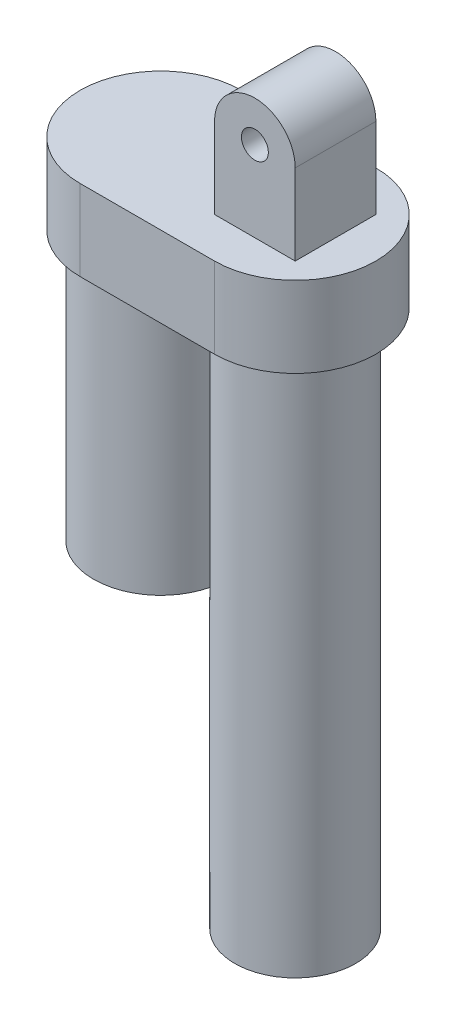
from build123d import *

# Parameters (mm, degrees)
ESBO_O1_W                = 13.5
ESBO_O1_H                = 200
RESSALTO_EXTRUS_O1_DEPTH = 30
ESBO_O3_W                = 25
ESBO_O3_H                = 100
ESBO_O4_R                = 5
RESSALTO_EXTRUS_O2_DEPTH = 15


with BuildPart() as part:
    # Esboço1 → Revolução1 (revolve)
    with BuildSketch(Plane.XY):
        with Locations((15.75, 100)):
            Rectangle(ESBO_O1_W, ESBO_O1_H)
    revolve(axis=Axis((0, 0, 0), (0, 1, 0)))

    # Esboço2 → Ressalto-extrusão1 (add)
    with BuildSketch(Plane(origin=(0, 200, 0), x_dir=(1, 0, 0), z_dir=(0, 1, 0))):
        with BuildLine():
            Line((0, -30), (-50, -30))
            ThreePointArc((-50, -30), (-80, 0), (-50, 30))
            Line((-50, 30), (0, 30))
            ThreePointArc((0, 30), (30, 0), (0, -30))
        make_face()
    extrude(amount=RESSALTO_EXTRUS_O1_DEPTH)

    # Esboço3 → Revolução2 (revolve)
    with BuildSketch(Plane.XY):
        with Locations((-37.5, 150)):
            Rectangle(ESBO_O3_W, ESBO_O3_H)
    revolve(axis=Axis((-50, 200, 0), (0, -1, 0)))

    # Esboço4 → Ressalto-extrusão2 (add, symmetric)
    with BuildSketch(Plane.XY):
        with BuildLine():
            Line((15, 230), (15, 260))
            ThreePointArc((15, 260), (0, 275), (-15, 260))
            Line((-15, 260), (-15, 230))
            Line((-15, 230), (15, 230))
        make_face()
        with Locations((0, 260)):
            Circle(ESBO_O4_R, mode=Mode.SUBTRACT)
    extrude(amount=RESSALTO_EXTRUS_O2_DEPTH, both=True)


solid = part.part
